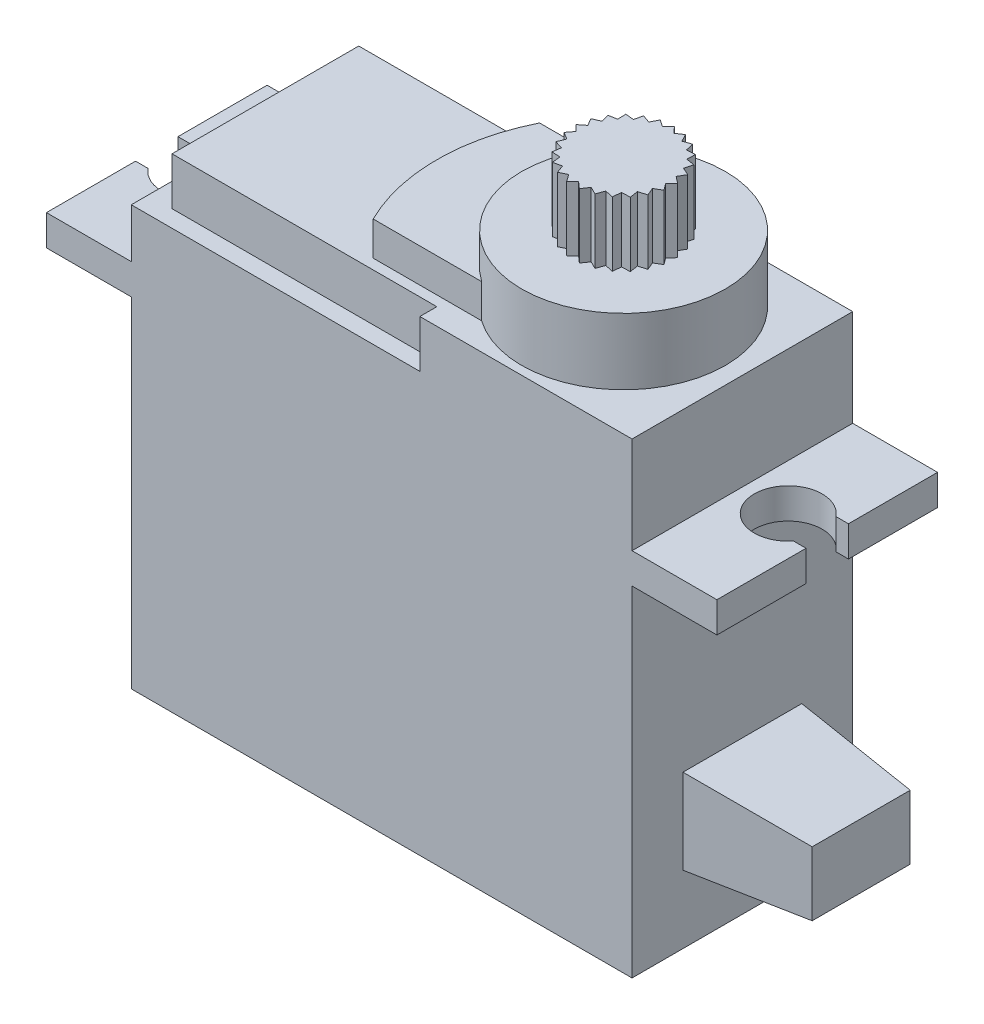
from build123d import *

# Parameters (mm, degrees)
BOSS_EXTRU_1_DEPTH            = 6.5
BOSS_EXTRU_1_DEPTH_BACK       = 6.5
ENL_V_MAT_EXTRU_1_DEPTH       = 2.8
ESQUISSE3_R                   = 6
BOSS_EXTRU_2_DEPTH            = 3.9
BOSS_EXTRU_3_DEPTH            = 3.8
BOSS_EXTRU_4_DEPTH            = 2
DIAM_TRE_DU_PER_AGE_4_0_4_1_D = 4
DIAM_TRE_DU_PER_AGE_4_0_4_2_D = 4
ESQUISSE10_W                  = 7
ESQUISSE10_H                  = 5
BOSS_EXTRU_5_DEPTH            = 7
D_POUILLE1_ANGLE              = 5
ESQUISSE11_W                  = 2
ESQUISSE11_H                  = 2.5
ENL_V_MAT_EXTRU_2_DEPTH       = 36.689494253
ENL_V_MAT_EXTRU_3_REACH       = 37.689
ESQUISSE12_W                  = 2
ESQUISSE12_H                  = 2.5


with BuildPart() as part:
    # Esquisse1 → Boss.-Extru.1 (new, two sides: drawn at the far end of the back side and taken through both)
    with BuildSketch(Plane.XY.offset(-BOSS_EXTRU_1_DEPTH_BACK)):
        Polygon((-22.5, -11.2), (-22.5, -31.2), (7, -31.2), (7, -11.2), (12, -11.2), (12, -9.4), (7, -9.4), (7, -3.7), (-22.5, -3.7), (-22.5, -9.4), (-27.5, -9.4), (-27.5, -11.2), align=None)
    extrude(amount=BOSS_EXTRU_1_DEPTH + BOSS_EXTRU_1_DEPTH_BACK)

    # Esquisse2 → Enlèv. mat.-Extru.1 (cut)
    with BuildSketch(Plane(origin=(0, -3.7, 0), x_dir=(1, 0, 0), z_dir=(0, 1, 0))):
        Polygon((-5.5, 6.5), (-5.5, 5.5), (-21.1, 5.5), (-21.1, -5.5), (-5.5, -5.5), (-5.5, -6.5), (-22.5, -6.5), (-22.5, 6.5), align=None)
    extrude(amount=-ENL_V_MAT_EXTRU_1_DEPTH, mode=Mode.SUBTRACT)

    # Esquisse3 → Boss.-Extru.2 (add)
    with BuildSketch(Plane(origin=(0, -3.7, 0), x_dir=(1, 0, 0), z_dir=(0, 1, 0))):
        Circle(ESQUISSE3_R)
    extrude(amount=BOSS_EXTRU_2_DEPTH)

    # Esquisse4 → Boss.-Extru.3 (add)
    with BuildSketch(Plane(origin=(0, 0.2, 0), x_dir=(1, 0, 0), z_dir=(0, 1, 0))):
        Polygon((0.332133069, 2.629103958), (0, 3), (-0.332133069, 2.629103958), (-0.746069661, 2.905749483), (-0.975530065, 2.463907688), (-1.445261022, 2.62892004), (-1.557630919, 2.143895035), (-2.053641318, 2.186905882), (-2.041860093, 1.689173573), (-2.532983777, 1.607480385), (-2.397791689, 1.128315123), (-2.853169549, 0.927050983), (-2.603061214, 0.496560484), (-2.994080185, 0.188371559), (-2.64477083, -0.166394877), (-2.946861752, -0.562143944), (-2.520299768, -0.818895035), (-2.714481157, -1.277337875), (-2.237469003, -1.419941007), (-2.311539728, -1.912271969), (-1.814049831, -1.931766863), (-1.763355757, -2.427050983), (-1.276647236, -2.322212702), (-1.104373658, -2.789329458), (-0.659028201, -2.566745377), (-0.375999701, -2.976344104), (0, -2.65), (0.375999701, -2.976344104), (0.659028201, -2.566745377), (1.104373658, -2.789329458), (1.276647236, -2.322212702), (1.763355757, -2.427050983), (1.814049831, -1.931766863), (2.311539728, -1.912271969), (2.237469003, -1.419941007), (2.714481157, -1.277337875), (2.520299768, -0.818895035), (2.946861752, -0.562143944), (2.64477083, -0.166394877), (2.994080185, 0.188371559), (2.603061214, 0.496560484), (2.853169549, 0.927050983), (2.397791689, 1.128315123), (2.532983777, 1.607480385), (2.041860093, 1.689173573), (2.053641318, 2.186905882), (1.557630919, 2.143895035), (1.445261022, 2.62892004), (0.975530065, 2.463907688), (0.746069661, 2.905749483), align=None)
    extrude(amount=BOSS_EXTRU_3_DEPTH)

    # Esquisse5 → Boss.-Extru.4 (add)
    with BuildSketch(Plane(origin=(0, -3.7, 0), x_dir=(1, 0, 0), z_dir=(0, 1, 0))):
        with BuildLine():
            Line((-9.848350116, 4.9), (0, 4.9))
            Line((0, 4.9), (0, -4.9))
            Line((0, -4.9), (-9.848350116, -4.9))
            ThreePointArc((-9.848350116, -4.9), (-11, 0), (-9.848350116, 4.9))
        make_face()
    extrude(amount=BOSS_EXTRU_4_DEPTH)

    # Diamètre du perçage Ø4.0 (4)1 (through all)
    with Locations(Plane(origin=(0, -9.4, 0), x_dir=(1, 0, 0), z_dir=(0, 1, 0))):
        with Locations((-25.2, 0)):
            Hole(DIAM_TRE_DU_PER_AGE_4_0_4_1_D / 2)

    # Diamètre du perçage Ø4.0 (4)2 (through all)
    with Locations(Plane(origin=(0, -9.4, 0), x_dir=(1, 0, 0), z_dir=(0, 1, 0))):
        with Locations((9.7, 0)):
            Hole(DIAM_TRE_DU_PER_AGE_4_0_4_2_D / 2)

    # Esquisse10 → Boss.-Extru.5 (add)
    with BuildSketch(Plane(origin=(7, 0, 0), x_dir=(0, 0, -1), z_dir=(1, 0, 0))):
        with Locations((0, -24.7)):
            Rectangle(ESQUISSE10_W, ESQUISSE10_H)
    extrude(amount=BOSS_EXTRU_5_DEPTH)

    # Dépouille1
    d_pouille1_faces = [part.faces().sort_by_distance(p)[0] for p in [
        (10.5, -27.2, 0),
        (10.5, -24.7, -3.5),
        (10.5, -22.2, 0),
        (10.5, -24.7, 3.5),
    ]]
    draft(d_pouille1_faces, Plane(origin=(7, -11.2, -6.5), x_dir=(0, 1, 0), z_dir=(1, 0, 0)), D_POUILLE1_ANGLE)

    # Esquisse11 → Enlèv. mat.-Extru.2 (cut, through all)
    with BuildSketch(Plane(origin=(0, -9.4, 0), x_dir=(1, 0, 0), z_dir=(0, 1, 0))):
        with Locations((-26.5, 0)):
            Rectangle(ESQUISSE11_W, ESQUISSE11_H)
    extrude(amount=-ENL_V_MAT_EXTRU_2_DEPTH, mode=Mode.SUBTRACT)

    # Esquisse12 → Enlèv. mat.-Extru.3 (cut, up to next)
    with BuildSketch(Plane(origin=(0, -9.4, 0), x_dir=(1, 0, 0), z_dir=(0, 1, 0)), mode=Mode.PRIVATE) as enl_v_mat_extru_3_sk1:
        with Locations((11, 0)):
            Rectangle(ESQUISSE12_W, ESQUISSE12_H)
    enl_v_mat_extru_3_tool1 = extrude(enl_v_mat_extru_3_sk1.sketch, amount=-ENL_V_MAT_EXTRU_3_REACH, mode=Mode.PRIVATE) & part.part
    add(enl_v_mat_extru_3_tool1.solids().sort_by_distance((11, -9.4, 0))[0], mode=Mode.SUBTRACT)


solid = part.part
